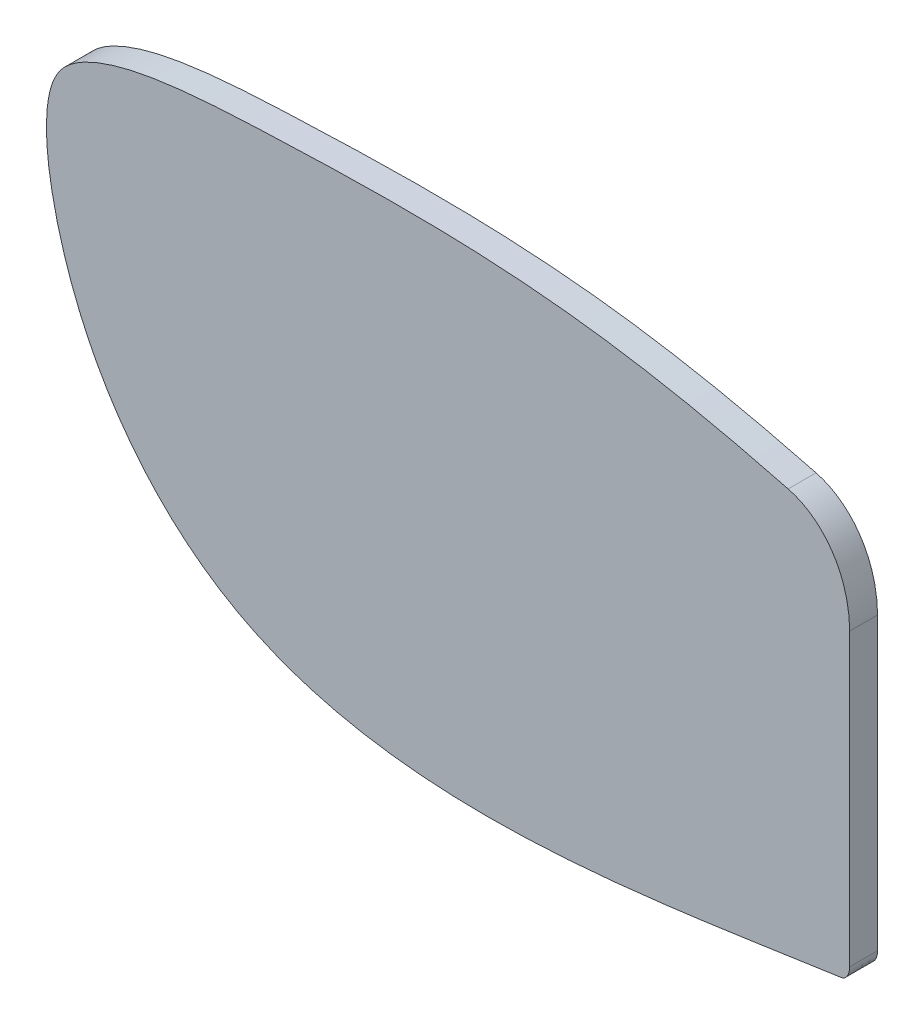
from build123d import *

# Parameters (mm, degrees)
BOSS_EXTRUDE1_DEPTH = 1


with BuildPart() as part:
    # Sketch1 → Boss-Extrude1 (new body)
    with BuildSketch(Plane.XY):
        with BuildLine():
            Line((-34.344904709, 22.453020705), (-34.344904709, 12.021294012))
            add(Edge.make_bspline(
                [(-34.344904709, 12.021294012), (-34.344904709, 11.950869966), (-34.369395323, 11.801041618), (-34.456887799, 11.64569221), (-34.556092402, 11.563502256), (-34.609785167, 11.545296913), (-34.640508554, 11.540921545)],
                knots=[0, 0, 0, 0, 0.25, 0.5, 0.75, 1, 1, 1, 1], degree=3))
            add(Edge.make_bspline(
                [(-34.640508554, 11.540921545), (-35.21724266, 11.458787884), (-36.338896606, 11.293164199), (-38.206863446, 11.015434655), (-40.163503445, 10.740869248), (-42.845789259, 10.413531021), (-46.229680272, 10.142800708), (-50.272137322, 10.223191), (-53.608133973, 10.854099917), (-56.122847013, 11.904931777), (-57.833316073, 12.998352576), (-59.357052902, 14.391461653), (-60.671081861, 16.053875197), (-61.722924964, 17.896690647), (-62.516219814, 19.897430235), (-63.043300892, 21.976334992), (-63.225144088, 23.743771435), (-63.030699507, 25.097013883), (-62.622246646, 25.876653231), (-61.840128752, 26.423806221), (-60.5910983, 26.917200473), (-58.886059289, 27.234833276), (-56.820169732, 27.404365552), (-54.721518229, 27.490361996), (-51.938200087, 27.584315306), (-48.491349327, 27.604148357), (-44.380700372, 27.336633874), (-41.01520735, 26.803048369), (-38.39470831, 26.232710485), (-37.171992655, 25.928130366), (-36.552758897, 25.766223197)],
                knots=[0, 0, 0, 0, 0.03125, 0.0625, 0.09375, 0.125, 0.1875, 0.25, 0.3125, 0.34375, 0.375, 0.40625, 0.4375, 0.46875, 0.5, 0.53125, 0.5625, 0.578125, 0.59375, 0.609375, 0.625, 0.65625, 0.6875, 0.71875, 0.75, 0.8125, 0.875, 0.9375, 0.96875, 1, 1, 1, 1], degree=3))
            add(Edge.make_bspline(
                [(-36.552758897, 25.766223197), (-36.246937061, 25.686261878), (-35.668156229, 25.415617429), (-34.957659811, 24.694102115), (-34.465184259, 23.683119271), (-34.344904709, 22.854280394), (-34.344904709, 22.453020705)],
                knots=[0, 0, 0, 0, 0.25, 0.5, 0.75, 1, 1, 1, 1], degree=3))
        make_face()
    extrude(amount=BOSS_EXTRUDE1_DEPTH)


solid = part.part
